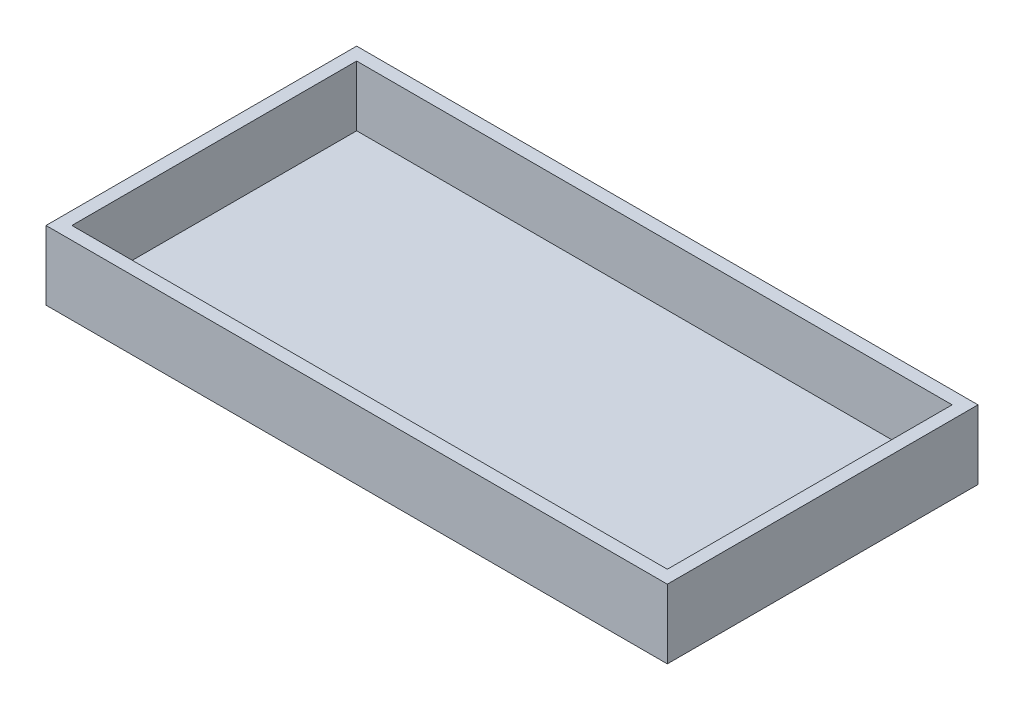
from build123d import *

# Parameters (mm, degrees)
SKETCH2_W           = 914.4
SKETCH2_H           = 457.2
BOSS_EXTRUDE2_DEPTH = 12.7
SKETCH1_W           = 914.4
SKETCH1_H           = 457.2
SKETCH1_W_2         = 876.3
SKETCH1_H_2         = 419.1
BOSS_EXTRUDE3_DEPTH = 88.9


with BuildPart() as part:
    # Sketch2 → Boss-Extrude2 (new body)
    with BuildSketch(Plane(origin=(0, 0, 0), x_dir=(1, 0, 0), z_dir=(0, 1, 0))):
        with Locations((457.2, 228.6)):
            Rectangle(SKETCH2_W, SKETCH2_H)
    extrude(amount=-BOSS_EXTRUDE2_DEPTH)

    # Sketch1 → Boss-Extrude3 (add)
    with BuildSketch(Plane(origin=(0, 0, 0), x_dir=(1, 0, 0), z_dir=(0, 1, 0))):
        with Locations((457.2, 228.6)):
            Rectangle(SKETCH1_W, SKETCH1_H)
        with Locations((457.2, 228.6)):
            Rectangle(SKETCH1_W_2, SKETCH1_H_2, mode=Mode.SUBTRACT)
    extrude(amount=BOSS_EXTRUDE3_DEPTH)


solid = part.part
